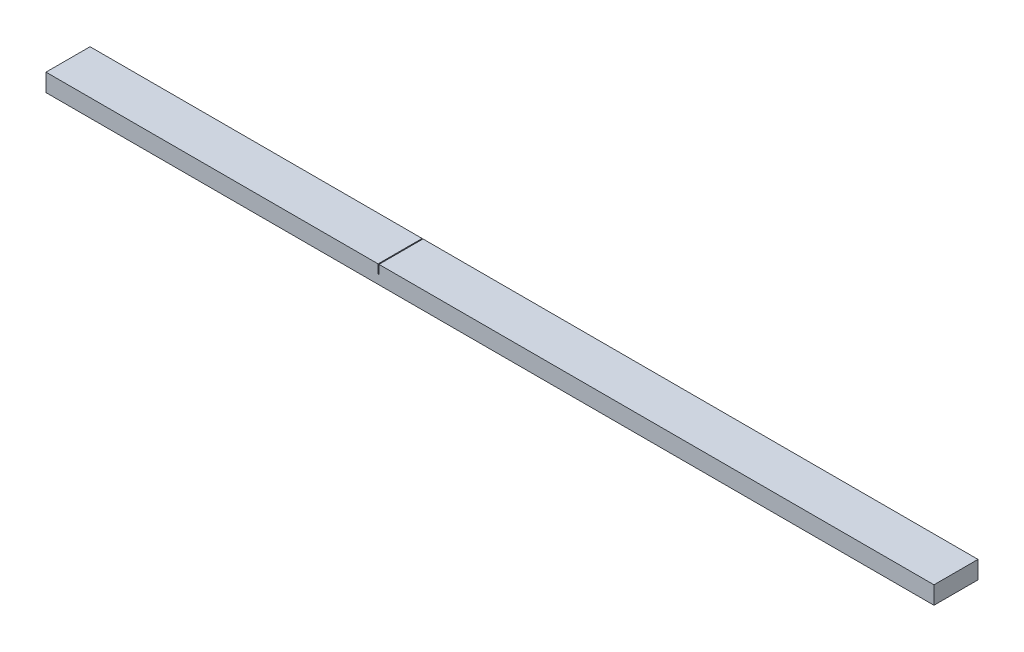
from build123d import *

# Parameters (mm, degrees)
SKETCH1_W           = 49.589064845
SKETCH1_H           = 20
BOSS_EXTRUDE1_DEPTH = 1000
SKETCH2_W           = 1
SKETCH2_H           = 49.589064845
CUT_EXTRUDE1_DEPTH  = 10


with BuildPart() as part:
    # Sketch1 → Boss-Extrude1 (new body)
    with BuildSketch(Plane(origin=(0, 0, 0), x_dir=(0, 0, -1), z_dir=(1, 0, 0))):
        with Locations((-2.30331722, 11.813768961)):
            Rectangle(SKETCH1_W, SKETCH1_H)
    extrude(amount=BOSS_EXTRUDE1_DEPTH)

    # Sketch2 → Cut-Extrude1 (cut)
    with BuildSketch(Plane(origin=(0, 21.813768961, 0), x_dir=(1, 0, 0), z_dir=(0, 1, 0))):
        with Locations((374.5, -2.30331722)):
            Rectangle(SKETCH2_W, SKETCH2_H)
    extrude(amount=-CUT_EXTRUDE1_DEPTH, mode=Mode.SUBTRACT)


solid = part.part
